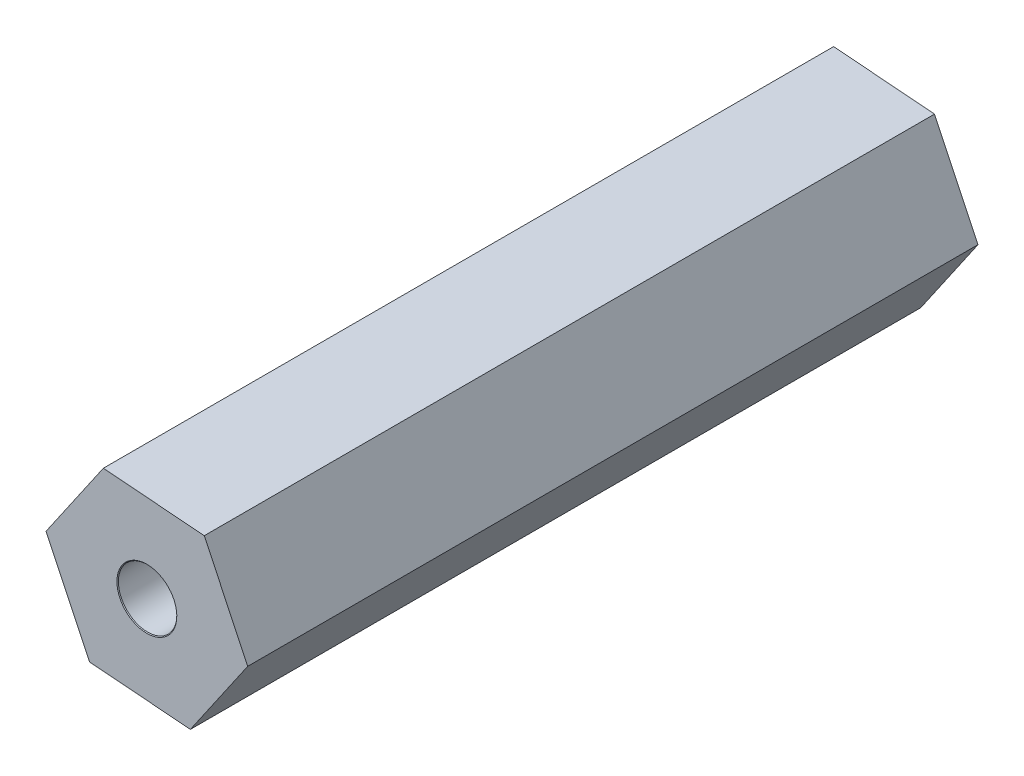
from build123d import *

# Parameters (mm, degrees)
BOSS_EXTRUDE1_DEPTH             = 25
F_2_0MM_DOWEL_HOLE1_D           = 2
F_2_0MM_DOWEL_HOLE1_DEPTH       = 25
F_2_0MM_DOWEL_HOLE1_CSINK_D     = 2.05
F_2_0MM_DOWEL_HOLE1_CSINK_ANGLE = 90
F_2_0MM_DOWEL_HOLE1_TIP         = 0.600860619


with BuildPart() as part:
    # Sketch1 → Boss-Extrude1 (new body)
    with BuildSketch(Plane.XY):
        Polygon((-60.488817819, 110.127846144), (-62.453203129, 107.27456902), (-60.964385311, 104.146722875), (-57.511182181, 103.872153856), (-55.546796871, 106.72543098), (-57.035614689, 109.853277125), align=None)
    extrude(amount=BOSS_EXTRUDE1_DEPTH)

    # Ø2.0mm Dowel Hole1
    with Locations(Plane(origin=(-59, 107, 25), x_dir=(1, 0, 0), z_dir=(0, 0, 1))):
        with Locations((0, 0)):
            CounterSinkHole(F_2_0MM_DOWEL_HOLE1_D / 2, F_2_0MM_DOWEL_HOLE1_CSINK_D / 2, depth=F_2_0MM_DOWEL_HOLE1_DEPTH, counter_sink_angle=F_2_0MM_DOWEL_HOLE1_CSINK_ANGLE)
            with Locations((0, 0, -(F_2_0MM_DOWEL_HOLE1_DEPTH + F_2_0MM_DOWEL_HOLE1_TIP / 2))):  # 118° drill point
                Cone(0, F_2_0MM_DOWEL_HOLE1_D / 2, F_2_0MM_DOWEL_HOLE1_TIP, mode=Mode.SUBTRACT)


solid = part.part
